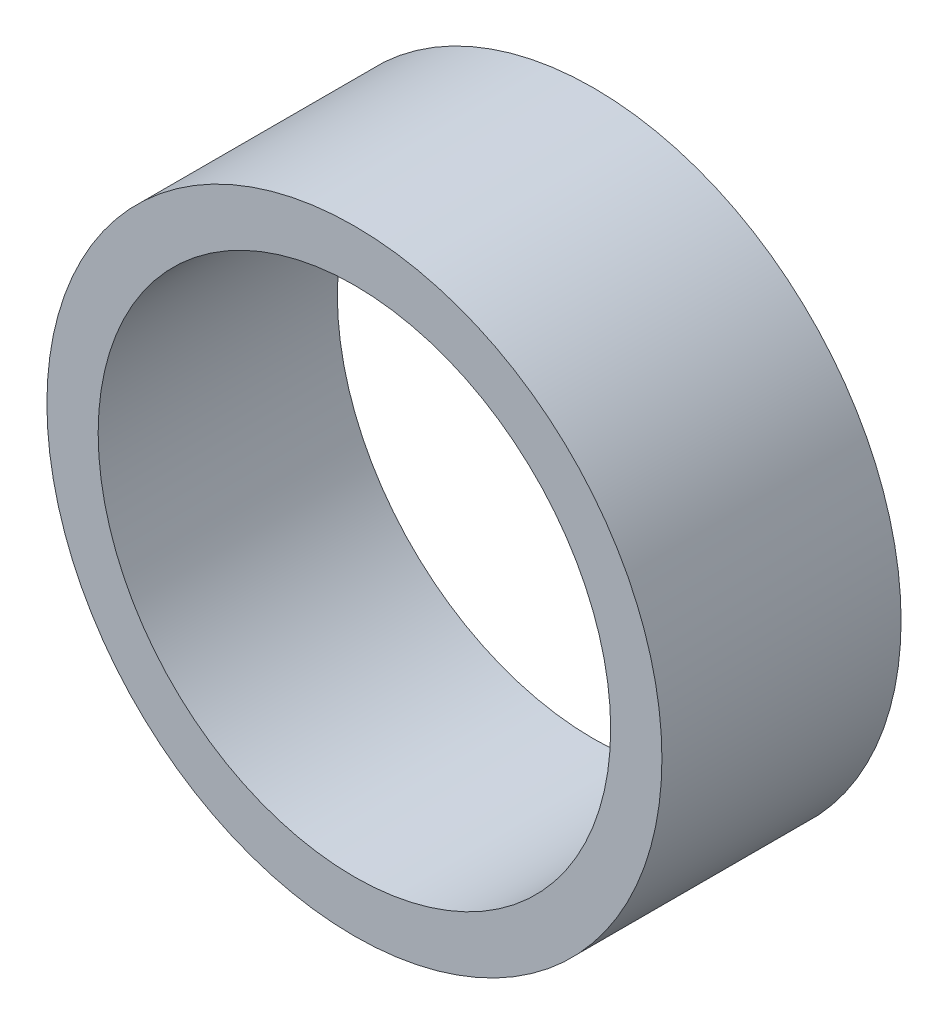
from build123d import *

# Parameters (mm, degrees)
ESQUISSE1_R        = 9
ESQUISSE1_R_2      = 7.5
BOSS_EXTRU_1_DEPTH = 7


with BuildPart() as part:
    # Esquisse1 → Boss.-Extru.1 (new body)
    with BuildSketch(Plane.XY):
        Circle(ESQUISSE1_R)
        Circle(ESQUISSE1_R_2, mode=Mode.SUBTRACT)
    extrude(amount=BOSS_EXTRU_1_DEPTH)


solid = part.part
